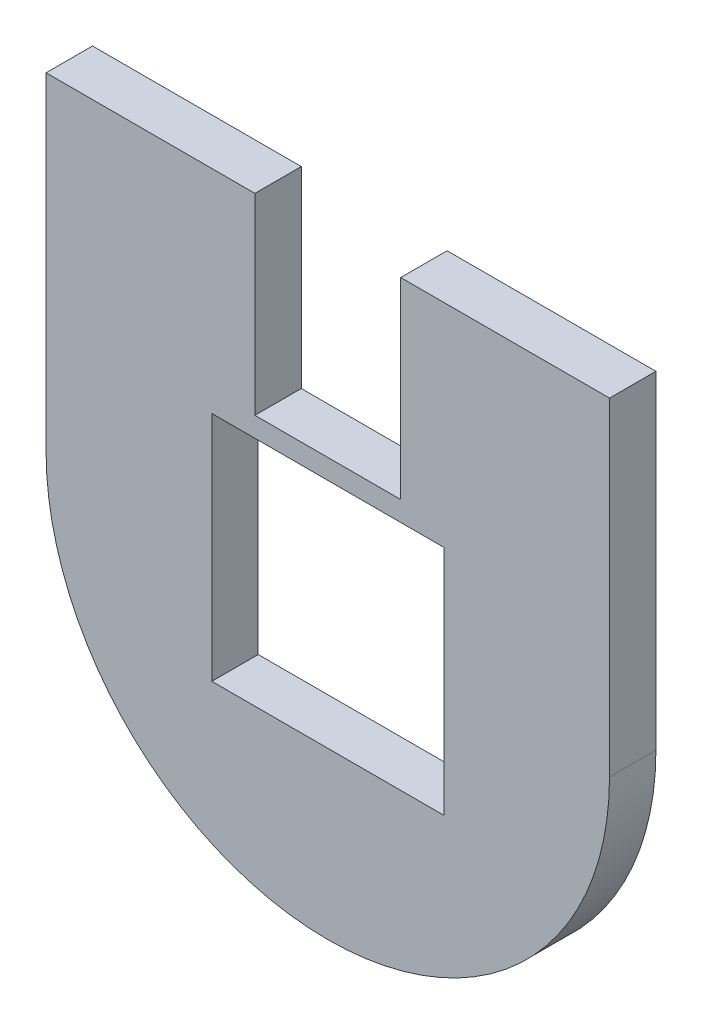
from build123d import *

# Parameters (mm, degrees)
SKETCH1_W           = 85
SKETCH1_H           = 95
BOSS_EXTRUDE1_DEPTH = 7
SKETCH2_W           = 35
SKETCH2_H           = 35
CUT_EXTRUDE1_DEPTH  = 7
CUT_EXTRUDE4_DEPTH  = 10
SKETCH12_W          = 22
SKETCH12_H          = 29.5
CUT_EXTRUDE9_DEPTH  = 10
SKETCH13_W          = 31.5
SKETCH13_H          = 7
CUT_EXTRUDE10_DEPTH = 0.5


with BuildPart() as part:
    # Sketch1 → Boss-Extrude1 (new body)
    with BuildSketch(Plane.XY):
        with Locations((42.5, 47.5)):
            Rectangle(SKETCH1_W, SKETCH1_H)
    extrude(amount=BOSS_EXTRUDE1_DEPTH)

    # Sketch2 → Cut-Extrude1 (cut)
    with BuildSketch(Plane.XY.offset(7)):
        with Locations((42.5, 45)):
            Rectangle(SKETCH2_W, SKETCH2_H)
    extrude(amount=-CUT_EXTRUDE1_DEPTH, mode=Mode.SUBTRACT)

    # Sketch7 → Cut-Extrude4 (cut)
    with BuildSketch(Plane(origin=(0, 0, 0), x_dir=(-1, 0, 0), z_dir=(0, 0, -1))):
        with BuildLine():
            Line((-85, 45), (-85, 0))
            Line((-85, 0), (0, 0))
            Line((0, 0), (0, 45))
            ThreePointArc((0, 45), (-42.5, 2.5), (-85, 45))
        make_face()
    extrude(amount=-CUT_EXTRUDE4_DEPTH, mode=Mode.SUBTRACT)

    # Sketch12 → Cut-Extrude9 (cut)
    with BuildSketch(Plane(origin=(0, 0, 0), x_dir=(-1, 0, 0), z_dir=(0, 0, -1))):
        with Locations((-42.5, 80.25)):
            Rectangle(SKETCH12_W, SKETCH12_H)
    extrude(amount=-CUT_EXTRUDE9_DEPTH, mode=Mode.SUBTRACT)

    # Sketch13 → Cut-Extrude10 (cut)
    with BuildSketch(Plane(origin=(0, 95, 0), x_dir=(1, 0, 0), z_dir=(0, 1, 0))):
        with Locations((15.75, -3.5)):
            Rectangle(SKETCH13_W, SKETCH13_H)
        with Locations((69.25, -3.5)):
            Rectangle(SKETCH13_W, SKETCH13_H)
    extrude(amount=-CUT_EXTRUDE10_DEPTH, mode=Mode.SUBTRACT)


solid = part.part
